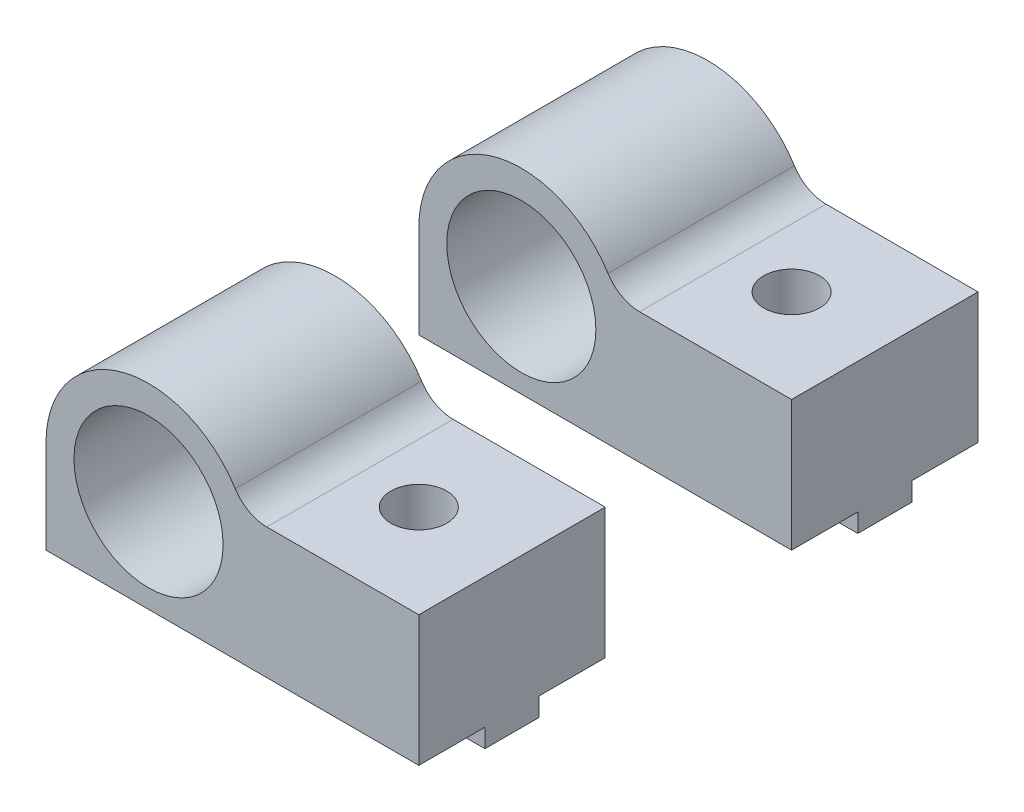
from build123d import *

# Parameters (mm, degrees)
SKETCH1_R                       = 4
MAIN_DEPTH                      = 10
SKETCH3_W                       = 20
SKETCH3_H                       = 2.9
MAKERBEAMRECTANGULARGUIDE_DEPTH = 1
SKETCH4_R                       = 1.5
MAKERBEAMFIXHOLE_DEPTH          = 9
FILLET1_R                       = 2
LPATTERN1_COUNT                 = 2
LPATTERN1_PITCH                 = 20


with BuildPart() as part:
    # Sketch1 → Main (new body)
    with BuildSketch(Plane.XY):
        with BuildLine():
            Line((-5.5, 0), (-5.5, -5))
            Line((-5.5, -5), (14.5, -5))
            Line((14.5, -5), (14.5, 2))
            Line((14.5, 2), (5.123475383, 2))
            ThreePointArc((5.123475383, 2), (-1.017567048, 5.405049242), (-5.5, 0))
        make_face()
        Circle(SKETCH1_R, mode=Mode.SUBTRACT)
    extrude(amount=MAIN_DEPTH)

    # Sketch3 → MakerBeamRectangularGuide (add)
    with BuildSketch(Plane(origin=(0, -5, 0), x_dir=(-1, 0, 0), z_dir=(0, -1, 0))):
        with Locations((-4.5, -5)):
            Rectangle(SKETCH3_W, SKETCH3_H)
    extrude(amount=MAKERBEAMRECTANGULARGUIDE_DEPTH)

    # Sketch4 → MakerBeamFixHole (cut, through all)
    with BuildSketch(Plane(origin=(0, 2, 0), x_dir=(1, 0, 0), z_dir=(0, 1, 0))):
        with Locations((9.5, -5)):
            Circle(SKETCH4_R)
    extrude(amount=-MAKERBEAMFIXHOLE_DEPTH, mode=Mode.SUBTRACT)

    # Fillet1
    fillet1_edges = [part.edges().sort_by_distance(p)[0] for p in [
        (5.123475383, 2, 5),
    ]]
    fillet(fillet1_edges, radius=FILLET1_R)


with BuildPart() as lpattern1_1:
    # LPattern1: pattern copy
    add(part.part.moved(Location(Vector(0, 0, -1) * (1 * LPATTERN1_PITCH))))


solid = Compound([part.part, lpattern1_1.part])
